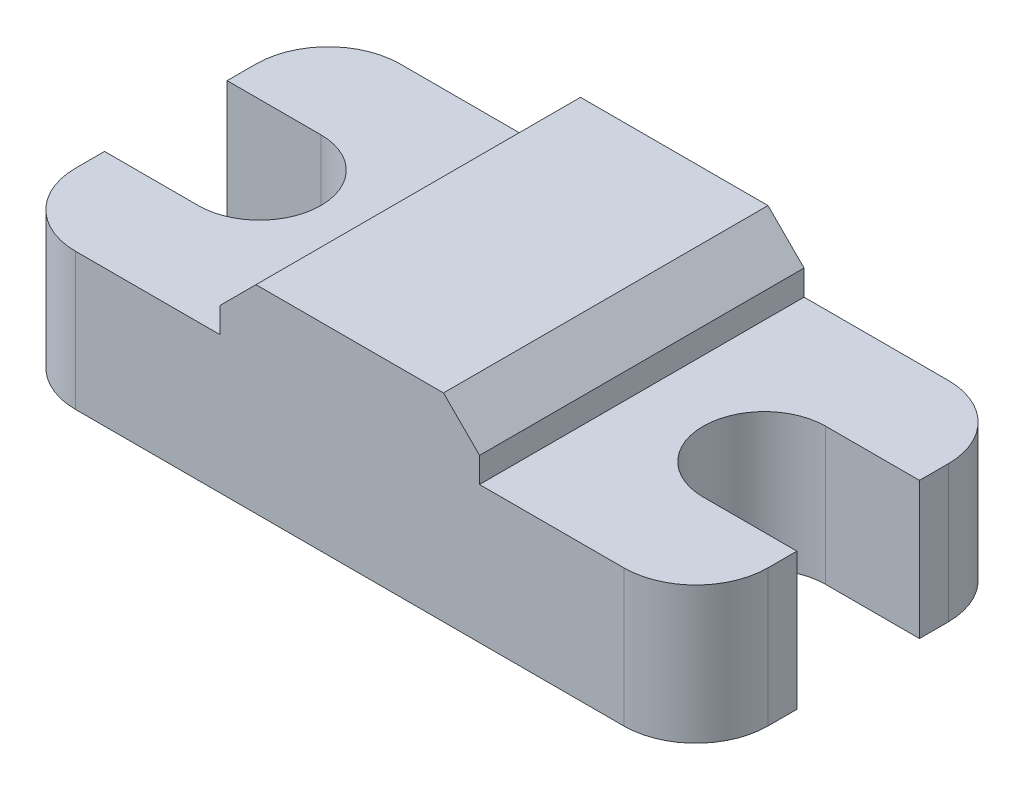
from build123d import *

# Parameters (mm, degrees)
BOSS_EXTRUDE1_DEPTH = 3.8
SKETCH3_W           = 7.2
SKETCH3_H           = 9
BOSS_EXTRUDE2_DEPTH = 1.7
CHAMFER1_SIZE       = 1


with BuildPart() as part:
    # Sketch1 → Boss-Extrude1 (new body)
    with BuildSketch(Plane(origin=(0, 0, 0), x_dir=(1, 0, 0), z_dir=(0, 1, 0))):
        with BuildLine():
            Line((0, 6.2), (2.6, 6.2))
            ThreePointArc((2.6, 6.2), (4.3, 4.5), (2.6, 2.8))
            Line((2.6, 2.8), (0, 2.8))
            Line((0, 2.8), (0, 2))
            ThreePointArc((0, 2), (0.585786438, 0.585786438), (2, 0))
            Line((2, 0), (17.2, 0))
            ThreePointArc((17.2, 0), (18.614213562, 0.585786438), (19.2, 2))
            Line((19.2, 2), (19.2, 2.8))
            Line((19.2, 2.8), (16.6, 2.8))
            ThreePointArc((16.6, 2.8), (14.9, 4.5), (16.6, 6.2))
            Line((16.6, 6.2), (19.2, 6.2))
            Line((19.2, 6.2), (19.2, 7))
            ThreePointArc((19.2, 7), (18.614213562, 8.414213562), (17.2, 9))
            Line((17.2, 9), (2, 9))
            ThreePointArc((2, 9), (0.585786438, 8.414213562), (0, 7))
            Line((0, 7), (0, 6.2))
        make_face()
    extrude(amount=BOSS_EXTRUDE1_DEPTH)

    # Sketch3 → Boss-Extrude2 (add)
    with BuildSketch(Plane(origin=(0, 3.8, 0), x_dir=(1, 0, 0), z_dir=(0, 1, 0))):
        with Locations((9.6, 4.5)):
            Rectangle(SKETCH3_W, SKETCH3_H)
    extrude(amount=BOSS_EXTRUDE2_DEPTH)

    # Chamfer1
    chamfer1_edges = [part.edges().sort_by_distance(p)[0] for p in [
        (13.2, 5.5, -4.5),
        (6, 5.5, -4.5),
    ]]
    chamfer(chamfer1_edges, length=CHAMFER1_SIZE)


solid = part.part
